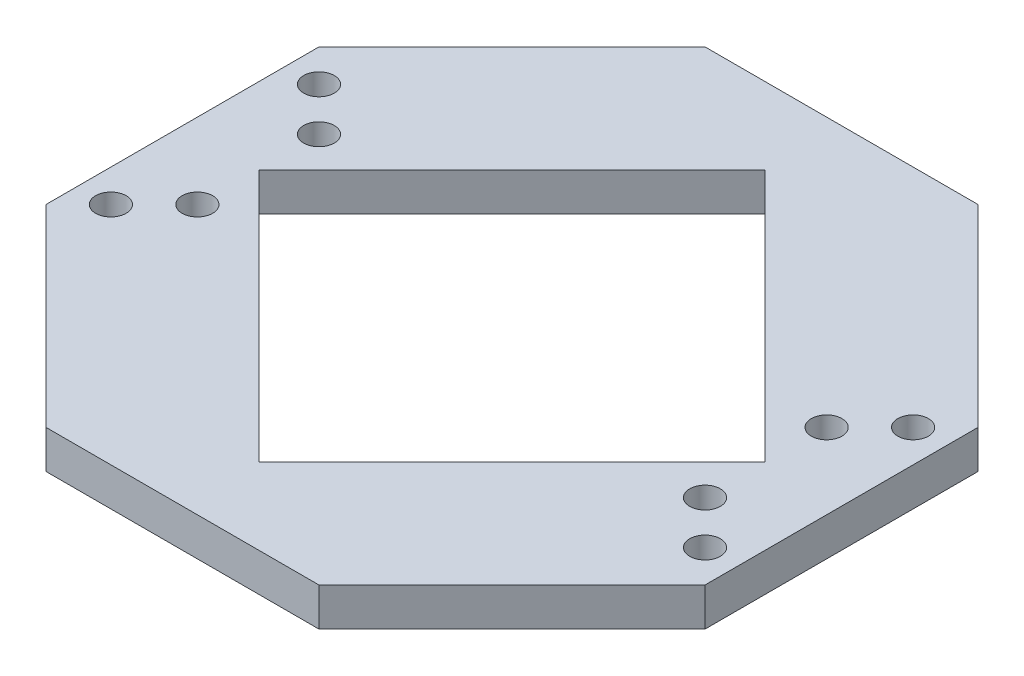
from build123d import *

# Parameters (mm, degrees)
BOSS_EXTRUDE1_DEPTH = 6.35
SKETCH2_R           = 2.54
CUT_EXTRUDE1_DEPTH  = 6.35


with BuildPart() as part:
    # Sketch1 → Boss-Extrude1 (new body)
    with BuildSketch(Plane(origin=(0, 0, 0), x_dir=(1, 0, 0), z_dir=(0, 1, 0))):
        Polygon((0, -42.037783588), (-42.037783588, 0), (-54.737783588, 0), (-54.737783588, -22.673132337), (-22.673132337, -54.737783588), (0, -54.737783588), align=None)
        Polygon((0, 42.037783588), (0, 54.737783588), (-22.673132337, 54.737783588), (-54.737783588, 22.673132337), (-54.737783588, 0), (-42.037783588, 0), align=None)
        Polygon((22.673132337, 54.737783588), (0, 54.737783588), (0, 42.037783588), (42.037783588, 0), (54.737783588, 0), (54.737783588, 22.673132337), align=None)
        Polygon((54.737783588, 0), (42.037783588, 0), (0, -42.037783588), (0, -54.737783588), (22.673132337, -54.737783588), (54.737783588, -22.673132337), align=None)
    extrude(amount=BOSS_EXTRUDE1_DEPTH)

    # Sketch2 → Cut-Extrude1 (cut)
    with BuildSketch(Plane(origin=(0, 6.35, 0), x_dir=(1, 0, 0), z_dir=(0, 1, 0))):
        with Locations((-49.349629916, 17.284978664)):
            Circle(SKETCH2_R)
        with Locations((-42.165425019, 10.100773767)):
            Circle(SKETCH2_R)
        with Locations((-49.349629916, -17.284978664)):
            Circle(SKETCH2_R)
        with Locations((-42.165425019, -10.100773767)):
            Circle(SKETCH2_R)
        with Locations((49.349629916, 17.284978664)):
            Circle(SKETCH2_R)
        with Locations((42.165425019, 10.100773767)):
            Circle(SKETCH2_R)
        with Locations((42.165425019, -10.100773767)):
            Circle(SKETCH2_R)
        with Locations((49.349629916, -17.284978664)):
            Circle(SKETCH2_R)
    extrude(amount=-CUT_EXTRUDE1_DEPTH, mode=Mode.SUBTRACT)


solid = part.part
